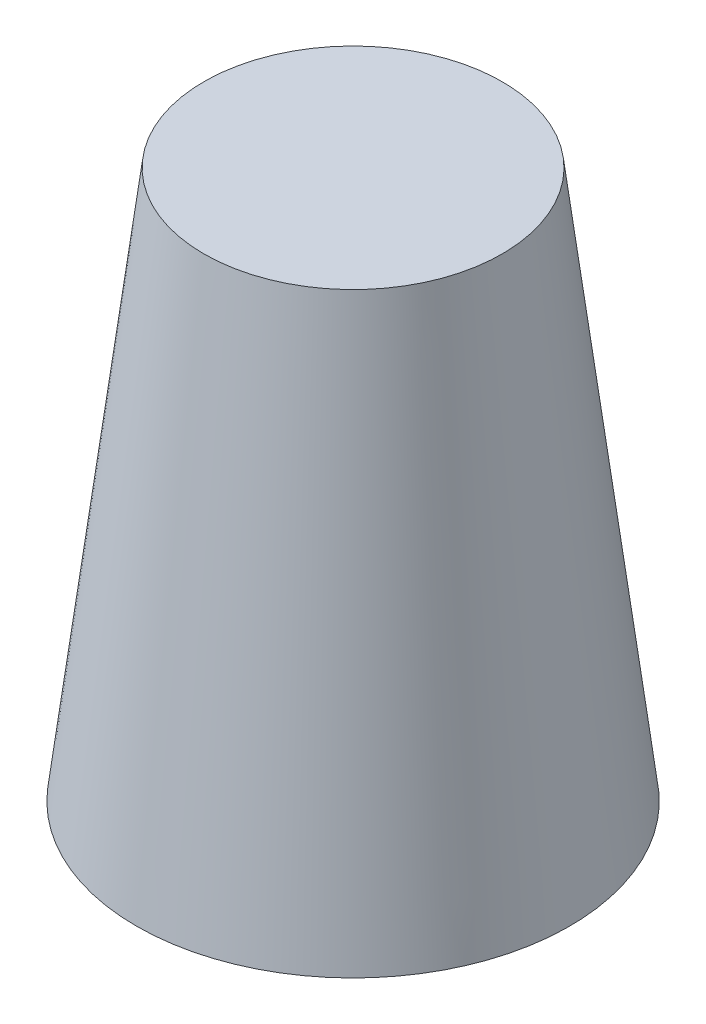
from build123d import *

# Parameters (mm, degrees)
SKETCH1_R           = 47.625
BOSS_EXTRUDE1_DEPTH = 120.65
BOSS_EXTRUDE1_TAPER = 7


with BuildPart() as part:
    # Sketch1 → Boss-Extrude1 (new body)
    with BuildSketch(Plane(origin=(0, 0, 0), x_dir=(1, 0, 0), z_dir=(0, 1, 0))):
        Circle(SKETCH1_R)
    extrude(amount=BOSS_EXTRUDE1_DEPTH, taper=BOSS_EXTRUDE1_TAPER)


solid = part.part
